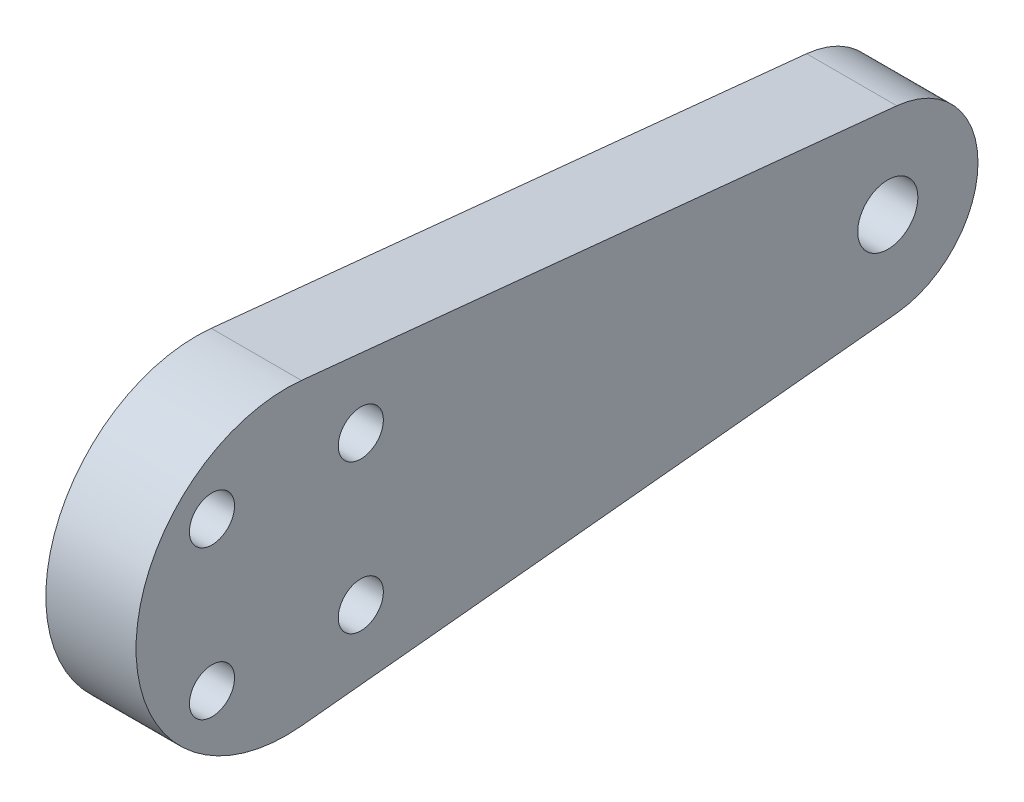
from build123d import *

# Parameters (mm, degrees)
SKETCH1_R               = 10
SKETCH1_R_2             = 6
BOSS_EXTRUDE1_DEPTH     = 3
CUT_EXTRUDE1_DEPTH      = 48.16990566
CUT_EXTRUDE1_DEPTH_BACK = 48.16990566
SKETCH2_R               = 1.5
F_4_0MM_DOWEL_HOLE1_D   = 4


with BuildPart() as part:
    # Sketch1 → Boss-Extrude1 (new, symmetric)
    with BuildSketch(Plane(origin=(0, 0, 0), x_dir=(0, 0, -1), z_dir=(1, 0, 0))):
        Circle(SKETCH1_R)
        with BuildLine():
            ThreePointArc((40.6, -5.969924623), (34, 0), (40.6, 5.969924623))
            Line((40.6, 5.969924623), (1, 9.949874371))
            ThreePointArc((1, 9.949874371), (7.416198487, 6.708203933), (10, 0))
            ThreePointArc((10, 0), (7.416198487, -6.708203933), (1, -9.949874371))
            Line((1, -9.949874371), (40.6, -5.969924623))
        make_face()
        with Locations((40, 0)):
            Circle(SKETCH1_R_2)
    extrude(amount=BOSS_EXTRUDE1_DEPTH, both=True)

    # Sketch2 → Cut-Extrude1 (cut, two sides: drawn at the far end of the back side and taken through both)
    with BuildSketch(Plane(origin=(0, 0, 0), x_dir=(0, 0, -1), z_dir=(1, 0, 0)).offset(-CUT_EXTRUDE1_DEPTH_BACK)):
        with Locations((4.949747468, 4.949747468)):
            Circle(SKETCH2_R)
        with Locations((4.949747468, -4.949747468)):
            Circle(SKETCH2_R)
        with Locations((-4.949747468, -4.949747468)):
            Circle(SKETCH2_R)
        with Locations((-4.949747468, 4.949747468)):
            Circle(SKETCH2_R)
    extrude(amount=CUT_EXTRUDE1_DEPTH + CUT_EXTRUDE1_DEPTH_BACK, mode=Mode.SUBTRACT)

    # Ø4.0mm Dowel Hole1 (through all)
    with Locations(Plane(origin=(3, 0, 0), x_dir=(0, 0, -1), z_dir=(1, 0, 0))):
        with Locations((40, 0)):
            Hole(F_4_0MM_DOWEL_HOLE1_D / 2)


solid = part.part
